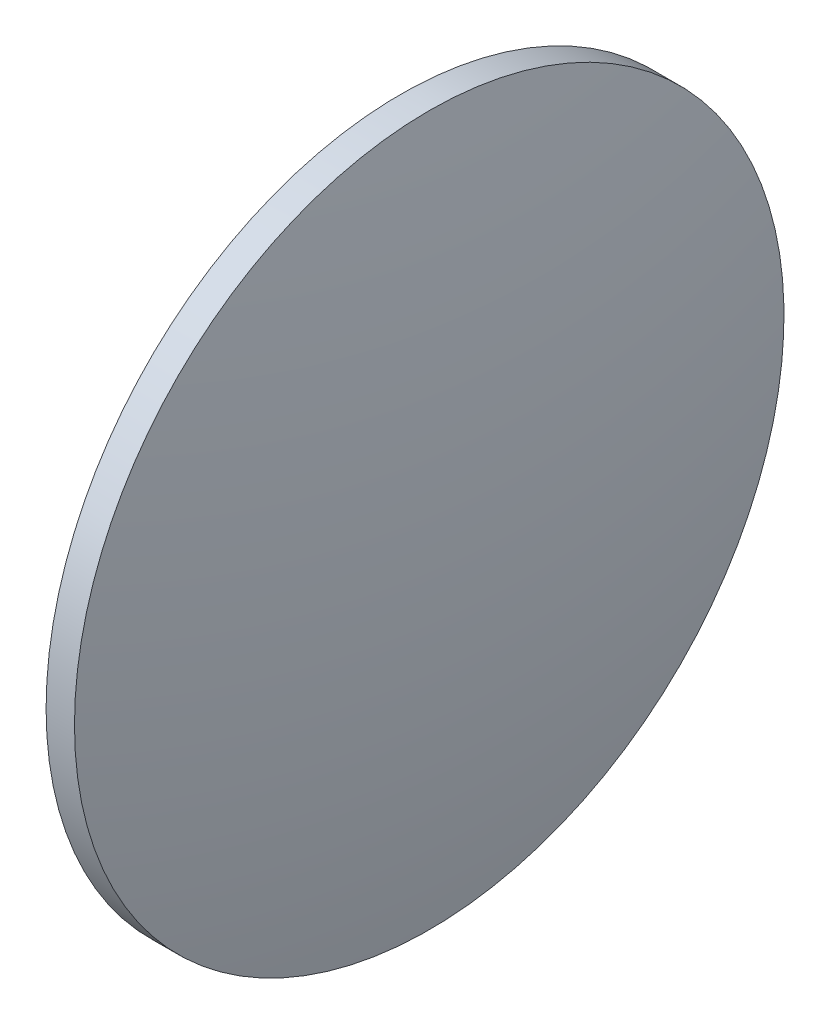
from build123d import *


with BuildPart() as part:
    # 草图2 → 旋转1 (revolve)
    with BuildSketch(Plane.XY):
        with BuildLine():
            Line((225.971347266, 130.467109853), (225.971347266, 180.467109853))
            Line((225.971347266, 180.467109853), (229.971347266, 180.467109853))
            ThreePointArc((229.971347266, 180.467109853), (233.635937909, 155.586385818), (234.861347266, 130.467109853))
            Line((234.861347266, 130.467109853), (225.971347266, 130.467109853))
        make_face()
    revolve(axis=Axis((217.994582532, 130.467109853, 0), (1, 0, 0)))


solid = part.part
